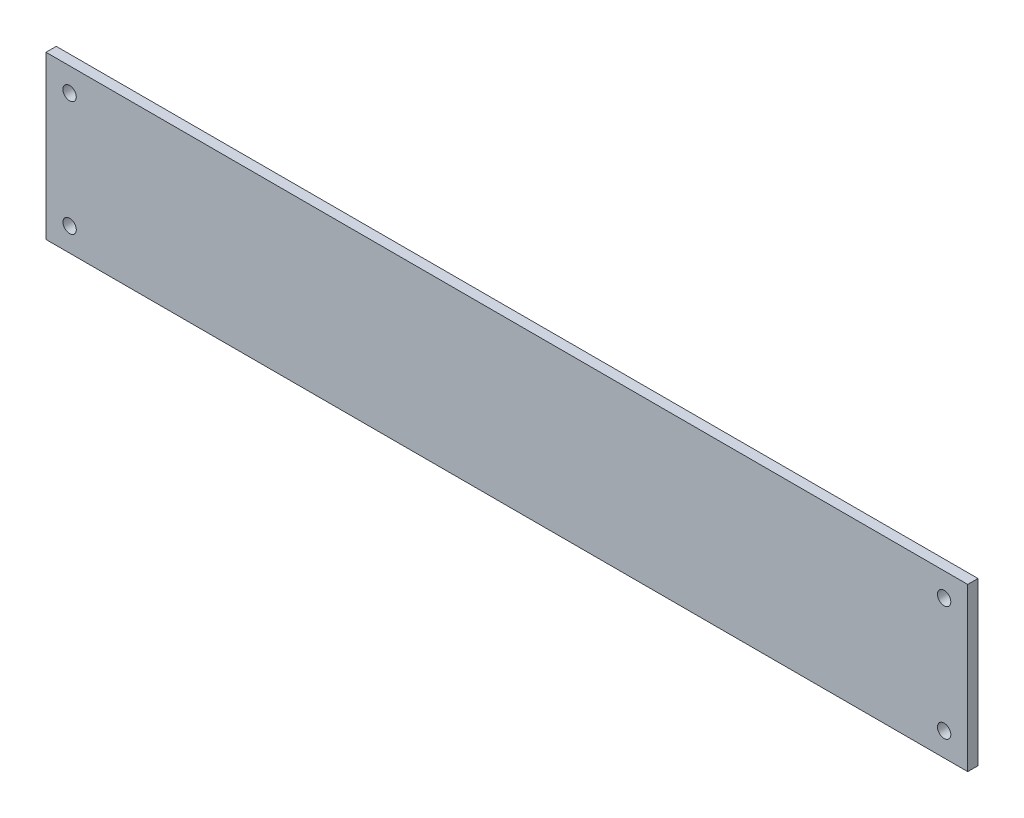
from build123d import *

# Parameters (mm, degrees)
SKETCH_F_W                   = 449
SKETCH_F_H                   = 79
SKETCH_F_R                   = 3.25
ESTRUSIONE_ESTRUSIONE1_DEPTH = 5


with BuildPart() as part:
    # Sketch f → Estrusione-Estrusione1 (new body)
    with BuildSketch(Plane.XY):
        with Locations((224.5, 39.5)):
            Rectangle(SKETCH_F_W, SKETCH_F_H)
        with Locations((11.5, 67.5)):
            Circle(SKETCH_F_R, mode=Mode.SUBTRACT)
        with Locations((437.5, 67.5)):
            Circle(SKETCH_F_R, mode=Mode.SUBTRACT)
        with Locations((11.5, 11.5)):
            Circle(SKETCH_F_R, mode=Mode.SUBTRACT)
        with Locations((437.5, 11.5)):
            Circle(SKETCH_F_R, mode=Mode.SUBTRACT)
    extrude(amount=ESTRUSIONE_ESTRUSIONE1_DEPTH)


solid = part.part
